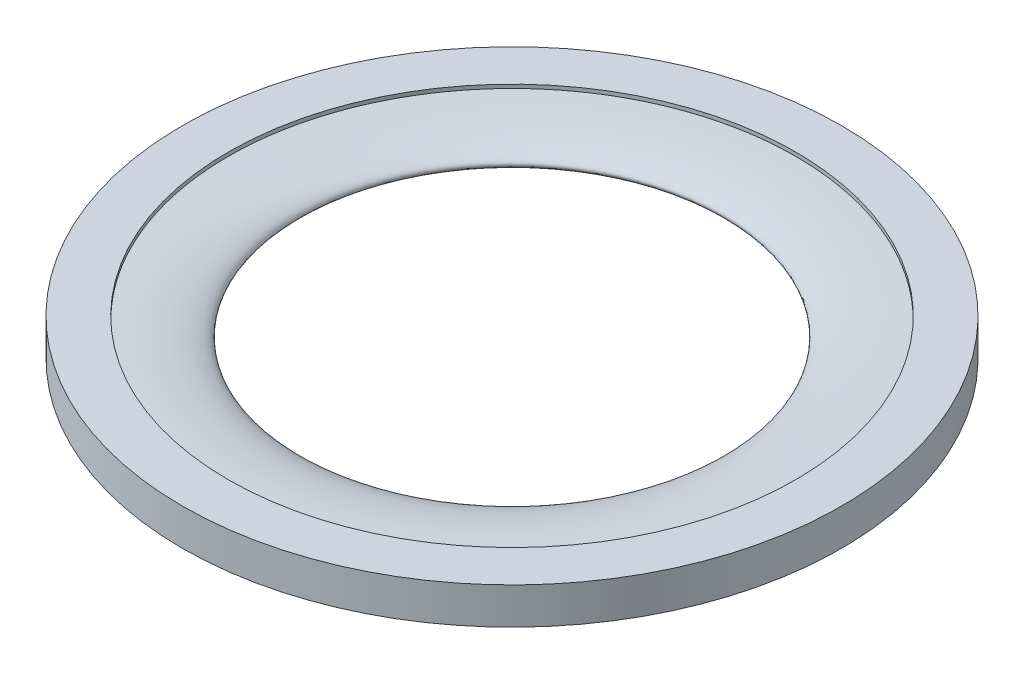
from build123d import *

# Parameters (mm, degrees)
SKETCH1_R           = 9
SKETCH1_R_2         = 7.75
BOSS_EXTRUDE1_DEPTH = 1


with BuildPart() as part:
    # Sketch1 → Boss-Extrude1 (new body)
    with BuildSketch(Plane(origin=(0, 0, 0), x_dir=(1, 0, 0), z_dir=(0, 1, 0))):
        Circle(SKETCH1_R)
        Circle(SKETCH1_R_2, mode=Mode.SUBTRACT)
    extrude(amount=BOSS_EXTRUDE1_DEPTH)


with BuildPart() as body_2:
    # Sketch3 → Revolve1 (revolve)
    with BuildSketch(Plane.XY):
        with BuildLine():
            Line((-7.75, 0.5), (-7.75, 0.1))
            add(Edge.make_bspline(
                [(-7.75, 0.1), (-5.75, 0.1), (-5.75, 0.5)],
                knots=[4.71238898, 4.71238898, 4.71238898, 6.283185307, 6.283185307, 6.283185307], degree=2, weights=[1, 0.707106781, 1]))
            Line((-5.75, 0.5), (-7.75, 0.5))
        make_face()
        with BuildLine():
            Line((-7.75, 0.9), (-7.75, 0.5))
            Line((-7.75, 0.5), (-5.75, 0.5))
            add(Edge.make_bspline(
                [(-5.75, 0.5), (-5.75, 0.9), (-7.75, 0.9)],
                knots=[6.283185307, 6.283185307, 6.283185307, 7.853981634, 7.853981634, 7.853981634], degree=2, weights=[1, 0.707106781, 1]))
        make_face()
    revolve(axis=Axis((0, 0, 0), (0, 1, 0)))


solid = Compound([part.part, body_2.part])
